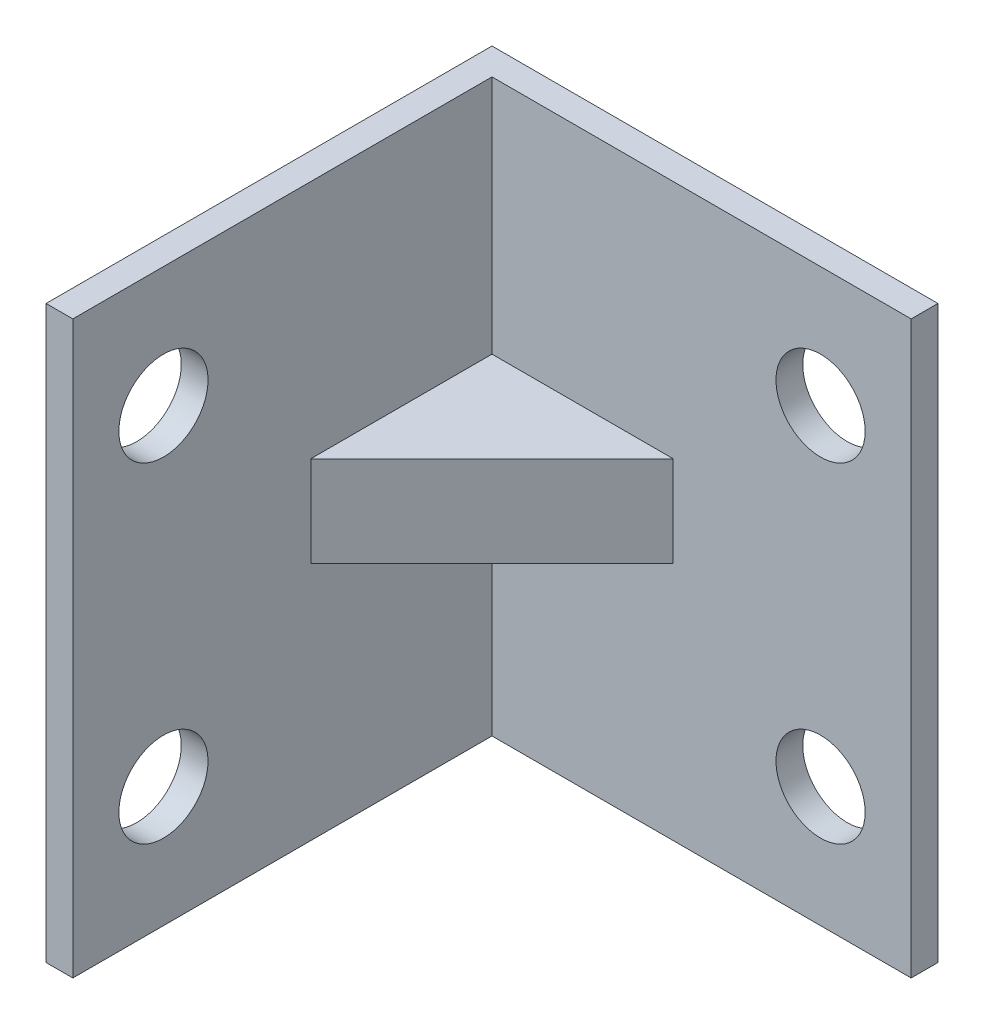
from build123d import *

# Parameters (mm, degrees)
SKETCH1_W                = 25
SKETCH1_H                = 32
SKETCH1_R                = 2.5
BOSS_EXTRUDE1_DEPTH      = 1.5
SKETCH2_W                = 25
SKETCH2_H                = 32
SKETCH2_R                = 2.5
BOSS_EXTRUDE2_DEPTH      = 1.5
BOSS_EXTRUDE3_DEPTH      = 2.54
BOSS_EXTRUDE3_DEPTH_BACK = 2.54


with BuildPart() as part:
    # Sketch1 → Boss-Extrude1 (new body)
    with BuildSketch(Plane.XY):
        Rectangle(SKETCH1_W, SKETCH1_H)
        with Locations((7.42, -9.25)):
            Circle(SKETCH1_R, mode=Mode.SUBTRACT)
        with Locations((7.42, 9.25)):
            Circle(SKETCH1_R, mode=Mode.SUBTRACT)
    extrude(amount=BOSS_EXTRUDE1_DEPTH)

    # Sketch2 → Boss-Extrude2 (add)
    with BuildSketch(Plane.ZY.offset(12.5)):
        with Locations((12.5, 0)):
            Rectangle(SKETCH2_W, SKETCH2_H)
        with Locations(Location((19.92, -9.25, 0), (0, 0, 270))):
            Circle(SKETCH2_R, mode=Mode.SUBTRACT)
        with Locations(Location((19.92, 9.25, 0), (0, 0, 270))):
            Circle(SKETCH2_R, mode=Mode.SUBTRACT)
    extrude(amount=-BOSS_EXTRUDE2_DEPTH)

    # Sketch3 → Boss-Extrude3 (add, two sides: drawn at the far end of the back side and taken through both)
    with BuildSketch(Plane(origin=(0, 0, 0), x_dir=(1, 0, 0), z_dir=(0, 1, 0)).offset(-BOSS_EXTRUDE3_DEPTH_BACK)):
        Polygon((-11, -1.5), (-11, -11.66), (-0.84, -1.5), align=None)
    extrude(amount=BOSS_EXTRUDE3_DEPTH + BOSS_EXTRUDE3_DEPTH_BACK)


solid = part.part
